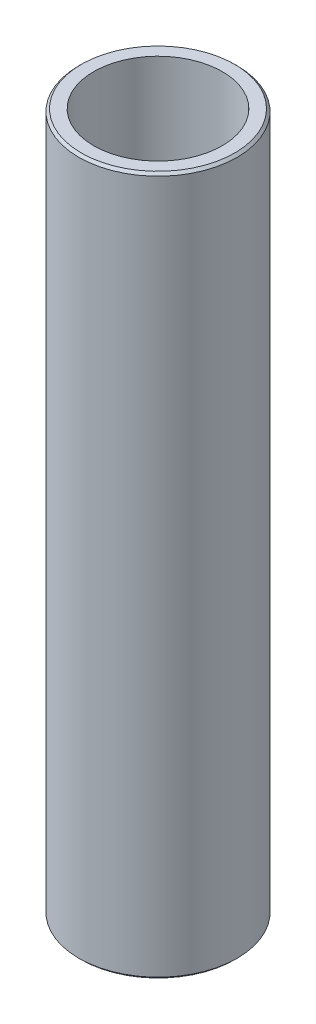
from build123d import *

# Parameters (mm, degrees)
SKETCH1_R           = 7.94
SKETCH1_R_2         = 6.44
BOSS_EXTRUDE1_DEPTH = 70
CHAMFER1_SIZE       = 0.25


with BuildPart() as part:
    # Sketch1 → Boss-Extrude1 (new body)
    with BuildSketch(Plane(origin=(0, 0, 0), x_dir=(1, 0, 0), z_dir=(0, 1, 0))):
        Circle(SKETCH1_R)
        Circle(SKETCH1_R_2, mode=Mode.SUBTRACT)
    extrude(amount=BOSS_EXTRUDE1_DEPTH)

    # Chamfer1
    chamfer1_edges = [part.edges().sort_by_distance(p)[0] for p in [
        (-7.94, 0, 0),
        (-7.94, 70, 0),
    ]]
    chamfer(chamfer1_edges, length=CHAMFER1_SIZE)


solid = part.part
